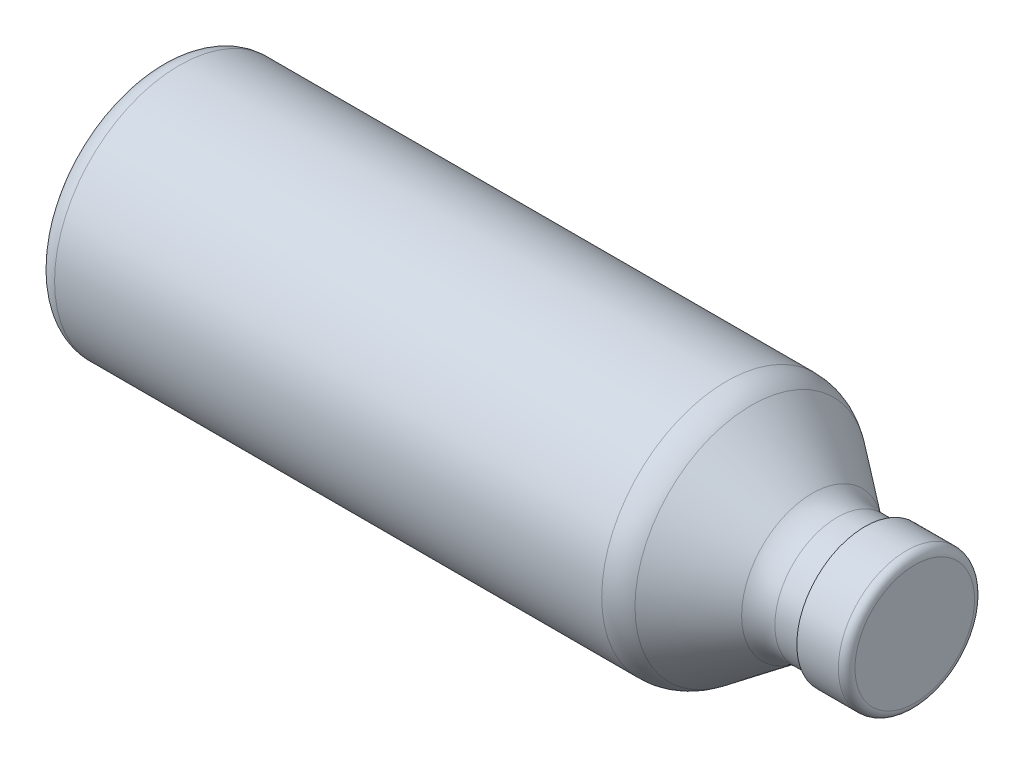
from build123d import *

# Parameters (mm, degrees)
FILLET_1_R      = 5
SHELL_1_T       = -1
EXTRUDE_START   = -10
SKETCH_2_R      = 16.391613339
SKETCH_2_R_2    = 15
EXTRUDE_1_DEPTH = 10
SKETCH_3_R      = 16.391613339
EXTRUDE_2_DEPTH = 2
FILLET_2_R      = 2


with BuildPart() as part:
    # 草图1 → 旋转1 (revolve)
    with BuildSketch(Plane.XY, mode=Mode.PRIVATE) as revolve_1_sk:
        with BuildLine():
            Line((180, 15), (163.333333333, 15))
            ThreePointArc((163.333333333, 15), (160.171055673, 15.513167019), (157.333333333, 17))
            Line((157.333333333, 17), (142.666666667, 28))
            ThreePointArc((142.666666667, 28), (139.828944327, 29.486832981), (136.666666667, 30))
            Line((136.666666667, 30), (0, 30))
            Line((0, 30), (0, 0))
            Line((0, 0), (180, 0))
            Line((180, 0), (180, 15))
        make_face()
    revolve(revolve_1_sk.sketch.rotate(Axis((0, 0, 0), (1, 0, 0)), 90), axis=Axis((0, 0, 0), (1, 0, 0)))

    # 圆角1
    fillet_1_edges = [part.edges().sort_by_distance(p)[0] for p in [
        (0, 0, -30),
    ]]
    fillet(fillet_1_edges, radius=FILLET_1_R)

    # 抽壳1
    shell_1_openings = [part.faces().sort_by_distance(p)[0] for p in [
        (180, 0, 0),
    ]]
    offset(amount=SHELL_1_T, openings=shell_1_openings, kind=Kind.INTERSECTION)

    # 草图2 → 凸台-拉伸1 (add)
    with BuildSketch(Plane(origin=(180, 0, 0), x_dir=(0, 0, -1), z_dir=(1, 0, 0)).offset(EXTRUDE_START)):
        Circle(SKETCH_2_R)
        with Locations(Location((0, 0, 0), (0, 0, 180))):
            Circle(SKETCH_2_R_2, mode=Mode.SUBTRACT)
    extrude(amount=EXTRUDE_1_DEPTH)

    # 草图3 → 凸台-拉伸2 (add)
    with BuildSketch(Plane(origin=(180, 0, 0), x_dir=(0, 0, -1), z_dir=(1, 0, 0))):
        Circle(SKETCH_3_R)
    extrude(amount=EXTRUDE_2_DEPTH)

    # 圆角2
    fillet_2_edges = [part.edges().sort_by_distance(p)[0] for p in [
        (182, 0, 16.391613339),
    ]]
    fillet(fillet_2_edges, radius=FILLET_2_R)


solid = part.part
